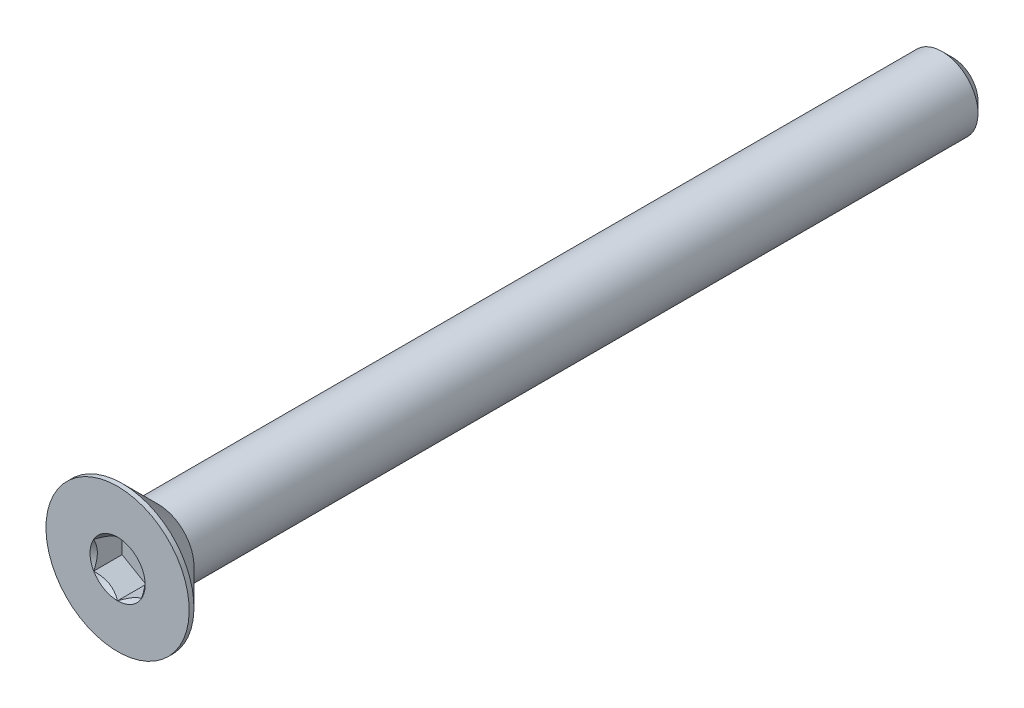
from build123d import *

# Parameters (mm, degrees)
SKETCH3_W          = 35
SKETCH3_H          = 1.5
CHAMFER1_SIZE      = 0.45
CUT_EXTRUDE1_DEPTH = 1.19


with BuildPart() as part:
    # Sketch3 → Revolve1 (revolve)
    with BuildSketch(Plane(origin=(0, 0, 0), x_dir=(0, 0, -1), z_dir=(1, 0, 0))):
        with Locations((0, 0.75)):
            Rectangle(SKETCH3_W, SKETCH3_H)
    revolve(axis=Axis((0, 0, -17.5), (0, 0, 1)))

    # Chamfer1
    chamfer1_edges = [part.edges().sort_by_distance(p)[0] for p in [
        (0, -1.5, -17.5),
    ]]
    chamfer(chamfer1_edges, length=CHAMFER1_SIZE)

    # Sketch6 → Revolve2 (revolve)
    with BuildSketch(Plane(origin=(0, 0, 0), x_dir=(0, 0, -1), z_dir=(1, 0, 0))):
        Polygon((-17.5, 3), (-17.3, 3), (-15.8, 1.5), (-15.8, 0), (-17.5, 0), align=None)
    revolve(axis=Axis((0, 0, -17.5), (0, 0, 1)))

    # Sketch8 → Cut-Extrude1 (cut)
    with BuildSketch(Plane.XY.offset(17.5)):
        Polygon((0, 1.154700538), (-1, 0.577350269), (-1, -0.577350269), (0, -1.154700538), (1, -0.577350269), (1, 0.577350269), align=None)
    extrude(amount=-CUT_EXTRUDE1_DEPTH, mode=Mode.SUBTRACT)

    # Cut-Extrude2 cone 1 section (through the dimple's axis) → Cut-Extrude2 (revolve, cut)
    with BuildSketch(Plane(origin=(0, 0, 17.5), x_dir=(0, -1, 0), z_dir=(1, 0, 0))):
        Polygon((0, 0), (1.154700538, 0), (0, 1.154700538), align=None)
    revolve(axis=Axis((0, 0, 17.5), (0, 0, -1)), mode=Mode.SUBTRACT)


solid = part.part
